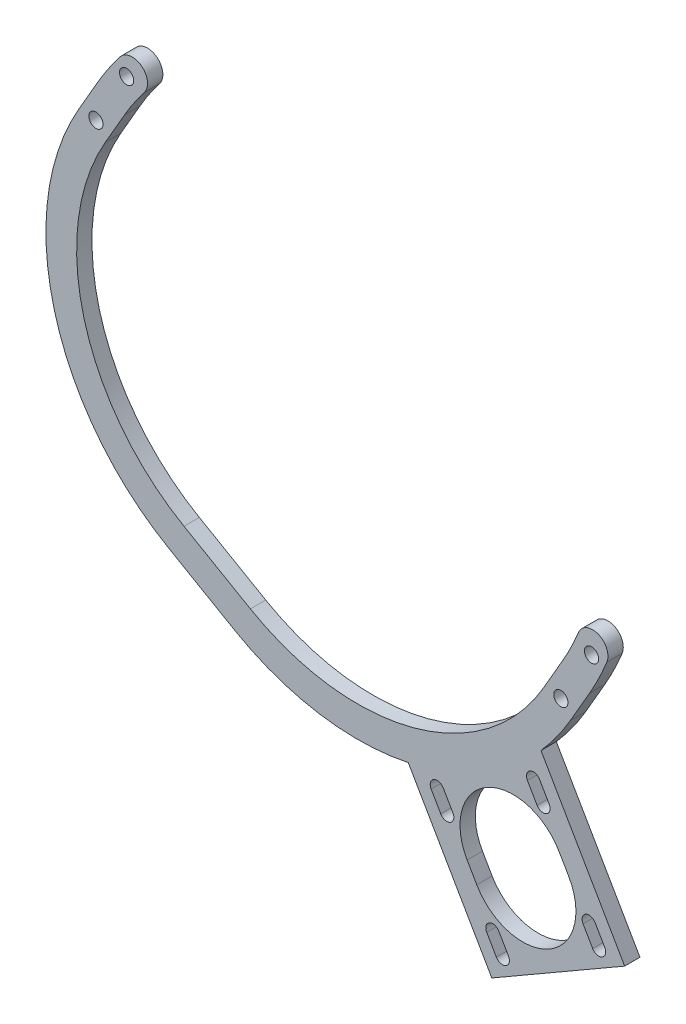
from build123d import *

# Parameters (mm, degrees)
BOSS_EXTRUDE1_DEPTH   = 3.175
F_4_CLEARANCE_HOLE1_D = 2.9464
BOSS_EXTRUDE2_DEPTH   = 3.175


with BuildPart() as part:
    # Sketch1 → Boss-Extrude1 (new body)
    with BuildSketch(Plane(origin=(0, 0, -14.15699402), x_dir=(-1, 0, 0), z_dir=(0, 0, -1))):
        with BuildLine():
            Line((-49.172312317, -34.502108483), (-53.141062317, -27.628031841))
            ThreePointArc((-53.141062317, -27.628031841), (-55.063803638, -24.012221257), (-56.72992661, -20.271224785))
            ThreePointArc((-56.72992661, -20.271224785), (-54.976138042, -16.13776671), (-50.842679967, -17.891555277))
            ThreePointArc((-50.842679967, -17.891555277), (-49.356678398, -21.228119699), (-47.641801003, -24.453031841))
            Line((-47.641801003, -24.453031841), (-43.673051003, -31.327108483))
            ThreePointArc((-43.673051003, -31.327108483), (-16.68272836, -52.037511462), (17.046778195, -47.596937682))
            Line((17.046778195, -47.596937682), (23.920854837, -43.628187682))
            Line((23.920854837, -43.628187682), (30.79493148, -39.659437682))
            ThreePointArc((30.79493148, -39.659437682), (51.505334458, -12.669115038), (47.064760678, 21.060391517))
            Line((47.064760678, 21.060391517), (43.096010678, 27.934468159))
            ThreePointArc((43.096010678, 27.934468159), (41.160593535, 31.032051618), (39.01404477, 33.987248938))
            ThreePointArc((39.01404477, 33.987248938), (39.561948355, 38.44382292), (44.018522337, 37.895919335))
            ThreePointArc((44.018522337, 37.895919335), (46.425258832, 34.58251628), (48.595271992, 31.109468159))
            Line((48.595271992, 31.109468159), (52.564021992, 24.235391517))
            ThreePointArc((52.564021992, 24.235391517), (57.638963455, -14.312615975), (33.96993148, -45.158698996))
            Line((33.96993148, -45.158698996), (27.095854837, -49.127448996))
            Line((27.095854837, -49.127448996), (20.221778195, -53.096198996))
            ThreePointArc((20.221778195, -53.096198996), (-18.326229296, -58.171140459), (-49.172312317, -34.502108483))
        make_face()
    extrude(amount=BOSS_EXTRUDE1_DEPTH)

    # 4 Clearance Hole1 (through all)
    with Locations(Plane(origin=(0, 0, -17.33199402), x_dir=(-1, 0, 0), z_dir=(0, 0, -1))):
        with Locations((-53.56643166, -20.541270527), (-47.21643166, -31.539793155), (42.670641335, 35.021229473), (49.020641335, 24.022706845)):
            Hole(F_4_CLEARANCE_HOLE1_D / 2)

    # Sketch6 → Boss-Extrude2 (add)
    with BuildSketch(Plane.XY.offset(-14.15699402)):
        Polygon((60.420653285, -72.901641316), (32.924346715, -88.776641316), (13.712730754, -55.501146376), (41.209037324, -39.626146376), align=None)
        with BuildLine():
            Line((46.862720596, -59.172213053), (48.856620596, -62.625749158))
            ThreePointArc((48.856620596, -62.625749158), (44.831, -77.649569754), (29.807179404, -73.623949158))
            Line((29.807179404, -73.623949158), (27.813279404, -70.170413053))
            ThreePointArc((27.813279404, -70.170413053), (31.8389, -55.146592457), (46.862720596, -59.172213053))
        make_face(mode=Mode.SUBTRACT)
        with BuildLine():
            Line((33.866506919, -84.566510659), (31.872606919, -81.112974554))
            ThreePointArc((31.872606919, -81.112974554), (32.402538499, -79.135242974), (34.380270079, -79.665174554))
            Line((34.380270079, -79.665174554), (36.374170079, -83.118710659))
            ThreePointArc((36.374170079, -83.118710659), (35.844238499, -85.096442239), (33.866506919, -84.566510659))
        make_face(mode=Mode.SUBTRACT)
        with BuildLine():
            Line((22.874070079, -59.735851552), (24.867970079, -63.189387657))
            ThreePointArc((24.867970079, -63.189387657), (24.338038499, -65.167119237), (22.360306919, -64.637187657))
            Line((22.360306919, -64.637187657), (20.366406919, -61.183651552))
            ThreePointArc((20.366406919, -61.183651552), (20.896338499, -59.205919972), (22.874070079, -59.735851552))
        make_face(mode=Mode.SUBTRACT)
        with BuildLine():
            Line((42.803393081, -48.229651552), (44.797293081, -51.683187657))
            ThreePointArc((44.797293081, -51.683187657), (44.267361501, -53.660919237), (42.289629921, -53.130987657))
            Line((42.289629921, -53.130987657), (40.295729921, -49.677451552))
            ThreePointArc((40.295729921, -49.677451552), (40.825661501, -47.699719972), (42.803393081, -48.229651552))
        make_face(mode=Mode.SUBTRACT)
        with BuildLine():
            Line((54.309593081, -68.158974554), (56.303493081, -71.612510659))
            ThreePointArc((56.303493081, -71.612510659), (55.773561501, -73.590242239), (53.795829921, -73.060310659))
            Line((53.795829921, -73.060310659), (51.801929921, -69.606774554))
            ThreePointArc((51.801929921, -69.606774554), (52.331861501, -67.629042974), (54.309593081, -68.158974554))
        make_face(mode=Mode.SUBTRACT)
    extrude(amount=-BOSS_EXTRUDE2_DEPTH)


solid = part.part
